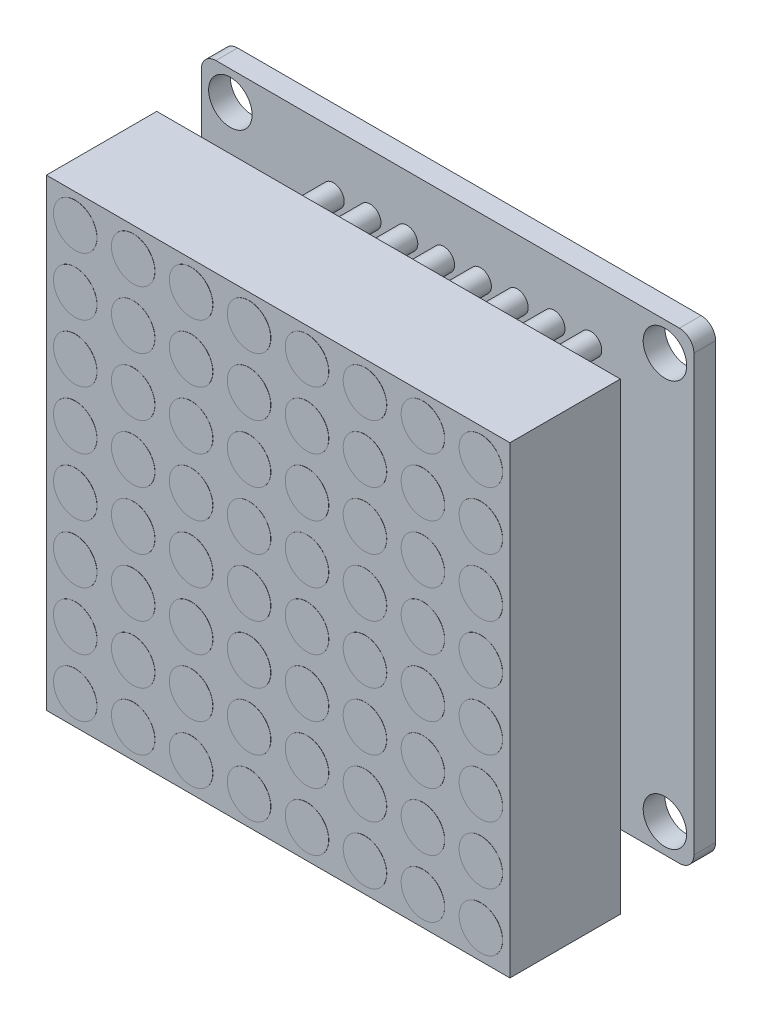
from build123d import *

# Parameters (mm, degrees)
CROQUIS1_R                   = 1.5
SALIENTE_EXTRUIR1_DEPTH      = 1.5
SALIENTE_EXTRUIR2_START      = -1.5
CROQUIS2_W                   = 2.54
CROQUIS2_H                   = 12.7
SALIENTE_EXTRUIR2_DEPTH      = 2.54
CROQUIS3_R                   = 0.75
SALIENTE_EXTRUIR3_DEPTH      = 2.54
CROQUIS4_W                   = 20.32
CROQUIS4_H                   = 2.4
SALIENTE_EXTRUIR4_DEPTH      = 2.54
CROQUIS5_R                   = 0.5
CORTAR_EXTRUIR1_DEPTH        = 1.27
CROQUIS6_W                   = 1
CROQUIS6_H                   = 1
SALIENTE_EXTRUIR6_DEPTH      = 5.08
SALIENTE_EXTRUIR6_DEPTH_BACK = 5.08
CROQUIS11_W                  = 32
CROQUIS11_H                  = 32
SALIENTE_EXTRUIR8_DEPTH      = 7.62
CROQUIS18_R                  = 1.5
SALIENTE_EXTRUIR9_DEPTH      = 0.01


with BuildPart() as part:
    # Croquis1 → Saliente-Extruir1 (new body)
    with BuildSketch(Plane.XY):
        with BuildLine():
            Line((-23.5, 16), (8.5, 16))
            ThreePointArc((8.5, 16), (9.207106781, 15.707106781), (9.5, 15))
            Line((9.5, 15), (9.5, -15))
            ThreePointArc((9.5, -15), (9.207106781, -15.707106781), (8.5, -16))
            Line((8.5, -16), (-23.5, -16))
            ThreePointArc((-23.5, -16), (-24.207106781, -15.707106781), (-24.5, -15))
            Line((-24.5, -15), (-24.5, 15))
            ThreePointArc((-24.5, 15), (-24.207106781, 15.707106781), (-23.5, 16))
        make_face()
        with Locations((-22.5, -14)):
            Circle(CROQUIS1_R, mode=Mode.SUBTRACT)
        with Locations((-22.5, 14)):
            Circle(CROQUIS1_R, mode=Mode.SUBTRACT)
        with Locations((7.5, 14)):
            Circle(CROQUIS1_R, mode=Mode.SUBTRACT)
        with Locations((7.5, -14)):
            Circle(CROQUIS1_R, mode=Mode.SUBTRACT)
    extrude(amount=SALIENTE_EXTRUIR1_DEPTH)

    # Croquis2 → Saliente-Extruir2 (add)
    with BuildSketch(Plane.XY.offset(1.5).offset(SALIENTE_EXTRUIR2_START)):
        with Locations((-23.13, 0)):
            Rectangle(CROQUIS2_W, CROQUIS2_H)
    extrude(amount=-SALIENTE_EXTRUIR2_DEPTH)

    # Croquis3 → Saliente-Extruir3 (add, symmetric)
    with BuildSketch(Plane.XY.offset(1.5)):
        with Locations((-15.39, 12)):
            Circle(CROQUIS3_R)
        with Locations((-12.85, 12)):
            Circle(CROQUIS3_R)
        with Locations((-10.31, 12)):
            Circle(CROQUIS3_R)
        with Locations((-7.77, 12)):
            Circle(CROQUIS3_R)
        with Locations((-5.23, 12)):
            Circle(CROQUIS3_R)
        with Locations((-2.69, 12)):
            Circle(CROQUIS3_R)
        with Locations((-0.15, 12)):
            Circle(CROQUIS3_R)
        with Locations((2.39, 12)):
            Circle(CROQUIS3_R)
        with Locations((2.39, -12)):
            Circle(CROQUIS3_R)
        with Locations((-0.15, -12)):
            Circle(CROQUIS3_R)
        with Locations((-2.69, -12)):
            Circle(CROQUIS3_R)
        with Locations((-5.23, -12)):
            Circle(CROQUIS3_R)
        with Locations((-7.77, -12)):
            Circle(CROQUIS3_R)
        with Locations((-10.31, -12)):
            Circle(CROQUIS3_R)
        with Locations((-12.85, -12)):
            Circle(CROQUIS3_R)
        with Locations((-15.39, -12)):
            Circle(CROQUIS3_R)
    extrude(amount=SALIENTE_EXTRUIR3_DEPTH, both=True)

    # Croquis4 → Saliente-Extruir4 (add)
    with BuildSketch(Plane.XY.offset(4.04)):
        with Locations((-6.5, 12)):
            Rectangle(CROQUIS4_W, CROQUIS4_H)
        with Locations((-6.5, -12)):
            Rectangle(CROQUIS4_W, CROQUIS4_H)
    extrude(amount=SALIENTE_EXTRUIR4_DEPTH)

    # Croquis5 → Cortar-Extruir1 (cut)
    with BuildSketch(Plane.XY.offset(6.58)):
        with Locations((-15.39, 12)):
            Circle(CROQUIS5_R)
        with Locations((-12.85, 12)):
            Circle(CROQUIS5_R)
        with Locations((-10.31, 12)):
            Circle(CROQUIS5_R)
        with Locations((-7.77, 12)):
            Circle(CROQUIS5_R)
        with Locations((-5.23, 12)):
            Circle(CROQUIS5_R)
        with Locations((-2.69, 12)):
            Circle(CROQUIS5_R)
        with Locations((-0.15, 12)):
            Circle(CROQUIS5_R)
        with Locations((2.39, 12)):
            Circle(CROQUIS5_R)
        with Locations((2.39, -12)):
            Circle(CROQUIS5_R)
        with Locations((-0.15, -12)):
            Circle(CROQUIS5_R)
        with Locations((-2.69, -12)):
            Circle(CROQUIS5_R)
        with Locations((-5.23, -12)):
            Circle(CROQUIS5_R)
        with Locations((-7.77, -12)):
            Circle(CROQUIS5_R)
        with Locations((-10.31, -12)):
            Circle(CROQUIS5_R)
        with Locations((-12.85, -12)):
            Circle(CROQUIS5_R)
        with Locations((-15.39, -12)):
            Circle(CROQUIS5_R)
    extrude(amount=-CORTAR_EXTRUIR1_DEPTH, mode=Mode.SUBTRACT)

    # Croquis6 → Saliente-Extruir6 (add, two sides)
    with BuildSketch(Plane(origin=(0, 0, -2.54), x_dir=(-1, 0, 0), z_dir=(0, 0, -1))) as saliente_extruir6_sk:
        with Locations((23.13, 5.08)):
            Rectangle(CROQUIS6_W, CROQUIS6_H)
        with Locations((23.13, 2.54)):
            Rectangle(CROQUIS6_W, CROQUIS6_H)
        with Locations((23.13, 0)):
            Rectangle(CROQUIS6_W, CROQUIS6_H)
        with Locations((23.13, -2.54)):
            Rectangle(CROQUIS6_W, CROQUIS6_H)
        with Locations((23.13, -5.08)):
            Rectangle(CROQUIS6_W, CROQUIS6_H)
    extrude(amount=SALIENTE_EXTRUIR6_DEPTH)
    extrude(saliente_extruir6_sk.sketch, amount=-SALIENTE_EXTRUIR6_DEPTH_BACK)

    # Croquis11 → Saliente-Extruir8 (add)
    with BuildSketch(Plane.XY.offset(6.58)):
        with Locations((-6.5, 0)):
            Rectangle(CROQUIS11_W, CROQUIS11_H)
    extrude(amount=SALIENTE_EXTRUIR8_DEPTH)

    # Croquis18 → Saliente-Extruir9 (add)
    with BuildSketch(Plane.XY.offset(14.2)):
        with Locations((-20.5, -14)):
            Circle(CROQUIS18_R)
        with Locations((-16.5, -14)):
            Circle(CROQUIS18_R)
        with Locations((-12.5, -14)):
            Circle(CROQUIS18_R)
        with Locations((-8.5, -14)):
            Circle(CROQUIS18_R)
        with Locations((-4.5, -14)):
            Circle(CROQUIS18_R)
        with Locations((-0.5, -14)):
            Circle(CROQUIS18_R)
        with Locations((3.5, -14)):
            Circle(CROQUIS18_R)
        with Locations((7.5, -14)):
            Circle(CROQUIS18_R)
        with Locations((-16.5, -10)):
            Circle(CROQUIS18_R)
        with Locations((-12.5, -10)):
            Circle(CROQUIS18_R)
        with Locations((-8.5, -10)):
            Circle(CROQUIS18_R)
        with Locations((-4.5, -10)):
            Circle(CROQUIS18_R)
        with Locations((-0.5, -10)):
            Circle(CROQUIS18_R)
        with Locations((3.5, -10)):
            Circle(CROQUIS18_R)
        with Locations((7.5, -10)):
            Circle(CROQUIS18_R)
        with Locations((-16.5, -6)):
            Circle(CROQUIS18_R)
        with Locations((-12.5, -6)):
            Circle(CROQUIS18_R)
        with Locations((-8.5, -6)):
            Circle(CROQUIS18_R)
        with Locations((-4.5, -6)):
            Circle(CROQUIS18_R)
        with Locations((-0.5, -6)):
            Circle(CROQUIS18_R)
        with Locations((3.5, -6)):
            Circle(CROQUIS18_R)
        with Locations((7.5, -6)):
            Circle(CROQUIS18_R)
        with Locations((-16.5, -2)):
            Circle(CROQUIS18_R)
        with Locations((-12.5, -2)):
            Circle(CROQUIS18_R)
        with Locations((-8.5, -2)):
            Circle(CROQUIS18_R)
        with Locations((-4.5, -2)):
            Circle(CROQUIS18_R)
        with Locations((-0.5, -2)):
            Circle(CROQUIS18_R)
        with Locations((3.5, -2)):
            Circle(CROQUIS18_R)
        with Locations((7.5, -2)):
            Circle(CROQUIS18_R)
        with Locations((-16.5, 2)):
            Circle(CROQUIS18_R)
        with Locations((-12.5, 2)):
            Circle(CROQUIS18_R)
        with Locations((-8.5, 2)):
            Circle(CROQUIS18_R)
        with Locations((-4.5, 2)):
            Circle(CROQUIS18_R)
        with Locations((-0.5, 2)):
            Circle(CROQUIS18_R)
        with Locations((3.5, 2)):
            Circle(CROQUIS18_R)
        with Locations((7.5, 2)):
            Circle(CROQUIS18_R)
        with Locations((-16.5, 6)):
            Circle(CROQUIS18_R)
        with Locations((-12.5, 6)):
            Circle(CROQUIS18_R)
        with Locations((-8.5, 6)):
            Circle(CROQUIS18_R)
        with Locations((-4.5, 6)):
            Circle(CROQUIS18_R)
        with Locations((-0.5, 6)):
            Circle(CROQUIS18_R)
        with Locations((3.5, 6)):
            Circle(CROQUIS18_R)
        with Locations((7.5, 6)):
            Circle(CROQUIS18_R)
        with Locations((-16.5, 10)):
            Circle(CROQUIS18_R)
        with Locations((-12.5, 10)):
            Circle(CROQUIS18_R)
        with Locations((-8.5, 10)):
            Circle(CROQUIS18_R)
        with Locations((-4.5, 10)):
            Circle(CROQUIS18_R)
        with Locations((-0.5, 10)):
            Circle(CROQUIS18_R)
        with Locations((3.5, 10)):
            Circle(CROQUIS18_R)
        with Locations((7.5, 10)):
            Circle(CROQUIS18_R)
        with Locations((-16.5, 14)):
            Circle(CROQUIS18_R)
        with Locations((-12.5, 14)):
            Circle(CROQUIS18_R)
        with Locations((-8.5, 14)):
            Circle(CROQUIS18_R)
        with Locations((-4.5, 14)):
            Circle(CROQUIS18_R)
        with Locations((-0.5, 14)):
            Circle(CROQUIS18_R)
        with Locations((3.5, 14)):
            Circle(CROQUIS18_R)
        with Locations((7.5, 14)):
            Circle(CROQUIS18_R)
        with Locations((-20.5, -10)):
            Circle(CROQUIS18_R)
        with Locations((-20.5, -6)):
            Circle(CROQUIS18_R)
        with Locations((-20.5, -2)):
            Circle(CROQUIS18_R)
        with Locations((-20.5, 2)):
            Circle(CROQUIS18_R)
        with Locations((-20.5, 6)):
            Circle(CROQUIS18_R)
        with Locations((-20.5, 10)):
            Circle(CROQUIS18_R)
        with Locations((-20.5, 14)):
            Circle(CROQUIS18_R)
    extrude(amount=SALIENTE_EXTRUIR9_DEPTH)


solid = part.part
